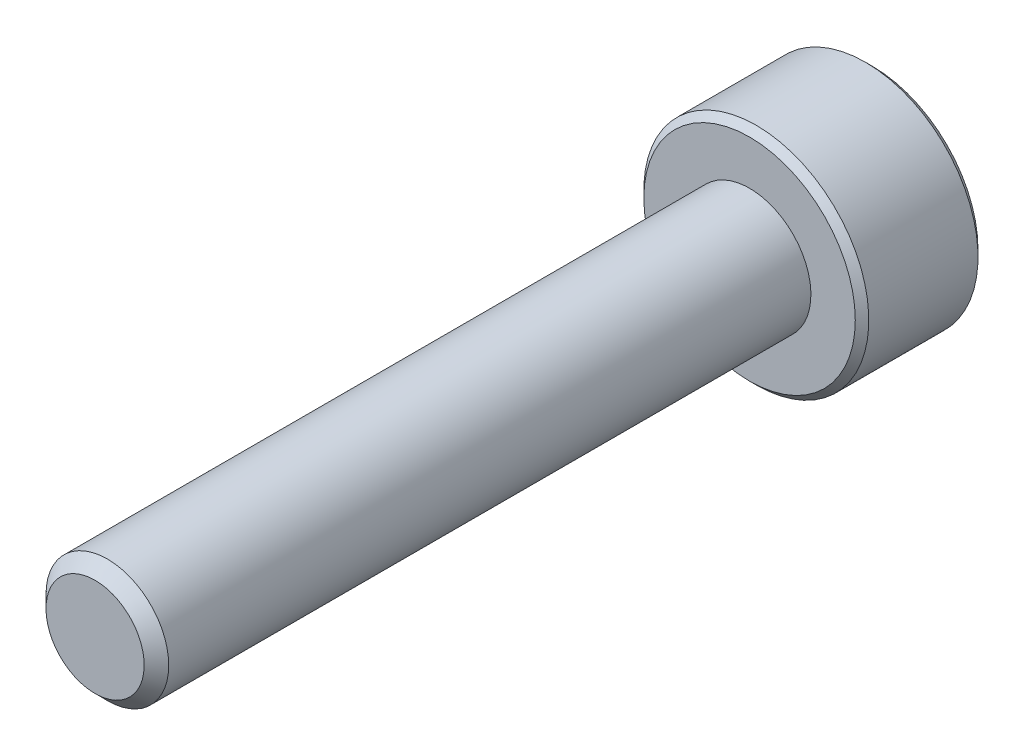
from build123d import *

# Parameters (mm, degrees)
CUT_EXTRUDE1_DEPTH = 1.875
CHAMFER1_SIZE      = 0.165
CHAMFER2_SIZE      = 0.3


with BuildPart() as part:
    # Sketch2 → Revolve1 (revolve)
    with BuildSketch(Plane(origin=(0, 0, 0), x_dir=(0, 0, -1), z_dir=(1, 0, 0))):
        Polygon((3, 2.75), (0, 2.75), (0, 1.5), (-16, 1.5), (-16, 0), (3, 0), align=None)
    revolve(axis=Axis((0, 0, 16), (0, 0, -1)))

    # Sketch4 → Cut-Extrude1 (cut)
    with BuildSketch(Plane(origin=(0, 0, -3), x_dir=(-1, 0, 0), z_dir=(0, 0, -1))):
        Polygon((0, 1.443375673), (-1.25, 0.721687836), (-1.25, -0.721687836), (0, -1.443375673), (1.25, -0.721687836), (1.25, 0.721687836), align=None)
    extrude(amount=-CUT_EXTRUDE1_DEPTH, mode=Mode.SUBTRACT)

    # Cut-Extrude2 cone 1 section (through the dimple's axis) → Cut-Extrude2 (revolve, cut)
    with BuildSketch(Plane(origin=(0, 0, -3), x_dir=(0, 1, 0), z_dir=(1, 0, 0))):
        Polygon((0, 0), (1.443375673, 0), (0, 1.443375673), align=None)
    revolve(axis=Axis((0, 0, -3), (0, 0, 1)), mode=Mode.SUBTRACT)

    # Chamfer1
    chamfer1_edges = [part.edges().sort_by_distance(p)[0] for p in [
        (0, -2.75, 0),
        (0, -2.75, -3),
    ]]
    chamfer(chamfer1_edges, length=CHAMFER1_SIZE)

    # Chamfer2
    chamfer2_edges = [part.edges().sort_by_distance(p)[0] for p in [
        (0, -1.5, 16),
    ]]
    chamfer(chamfer2_edges, length=CHAMFER2_SIZE)


solid = part.part
